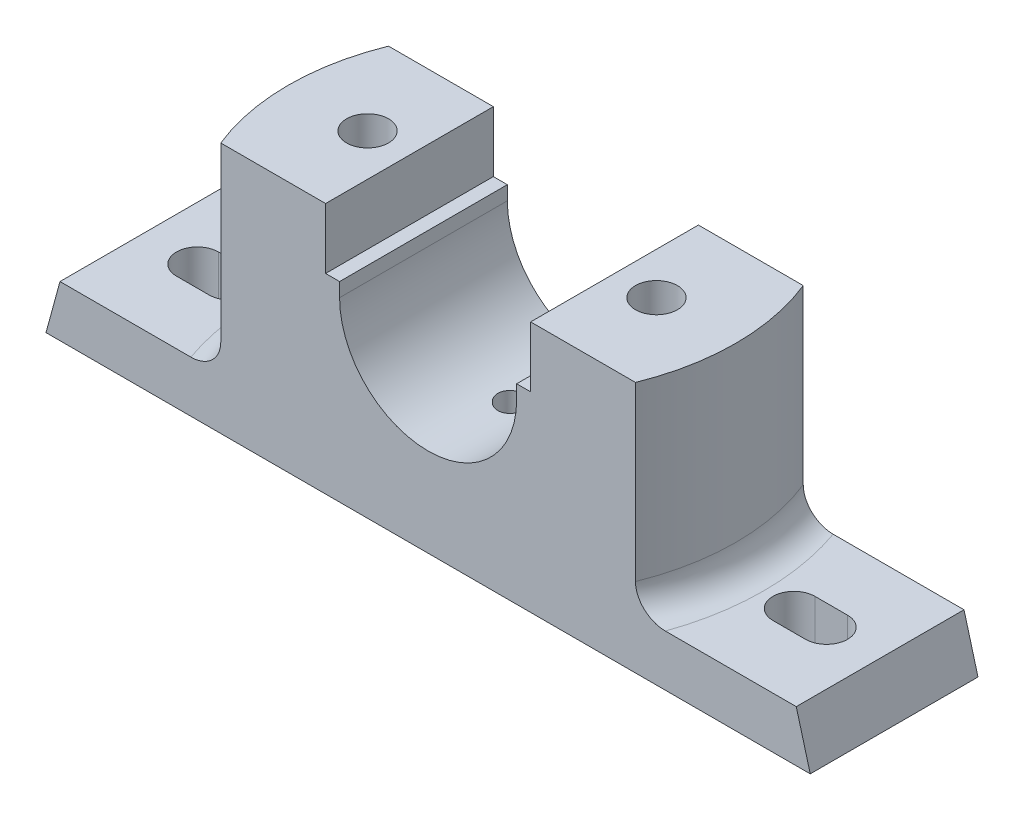
from build123d import *

# Parameters (mm, degrees)
BOSS_EXTRUDE1_DEPTH       = 18
CUT_EXTRUDE1_DEPTH        = 43
CUT_EXTRUDE2_DEPTH        = 12
SKETCH4_R                 = 4.5
CUT_EXTRUDE3_DEPTH        = 55
FILLET1_R                 = 6
SKETCH7_W                 = 20
SKETCH7_H                 = 20
CUT_EXTRUDE4_DEPTH        = 8
F_6_0MM_DOWEL_HOLE2_D     = 6
F_6_0MM_DOWEL_HOLE2_DEPTH = 6
F_6_0MM_DOWEL_HOLE2_TIP   = 1.802581857


with BuildPart() as part:
    # Sketch1 → Boss-Extrude1 (new body, symmetric)
    with BuildSketch(Plane.XY):
        with BuildLine():
            Line((-19, 3), (-22, 3))
            Line((-22, 3), (-22, 16))
            Line((-22, 16), (-50, 16))
            Line((-50, 16), (-50, -27))
            Line((-50, -27), (-79, -27))
            Line((-79, -27), (-82, -38))
            Line((-82, -38), (82, -38))
            Line((82, -38), (79, -27))
            Line((79, -27), (50, -27))
            Line((50, -27), (50, 16))
            Line((50, 16), (22, 16))
            Line((22, 16), (22, 3))
            Line((22, 3), (19, 3))
            Line((19, 3), (19, 0))
            ThreePointArc((19, 0), (0, -19), (-19, 0))
            Line((-19, 0), (-19, 3))
        make_face()
    extrude(amount=BOSS_EXTRUDE1_DEPTH, both=True)

    # Sketch2 → Cut-Extrude1 (cut)
    with BuildSketch(Plane(origin=(0, 16, 0), x_dir=(1, 0, 0), z_dir=(0, 1, 0))):
        with BuildLine():
            Line((-44.497190923, 18), (-50, 18))
            Line((-50, 18), (-50, -18))
            Line((-50, -18), (-44.497190923, -18))
            ThreePointArc((-44.497190923, -18), (-48, 0), (-44.497190923, 18))
        make_face()
    cut_extrude1 = extrude(amount=-CUT_EXTRUDE1_DEPTH, mode=Mode.SUBTRACT)

    # Mirror1: Cut-Extrude1 across plane
    add(cut_extrude1.mirror(Plane(origin=(0, 0, 0), x_dir=(0, 0, 1), z_dir=(1, 0, 0))), mode=Mode.SUBTRACT)

    # Sketch3 → Cut-Extrude2 (cut, through all)
    with BuildSketch(Plane(origin=(0, -27, 0), x_dir=(1, 0, 0), z_dir=(0, 1, 0))):
        with BuildLine():
            Line((-67.5, 4.5), (-60.5, 4.5))
            ThreePointArc((-60.5, 4.5), (-56, 0), (-60.5, -4.5))
            Line((-60.5, -4.5), (-67.5, -4.5))
            ThreePointArc((-67.5, -4.5), (-72, 0), (-67.5, 4.5))
        make_face()
    cut_extrude2 = extrude(amount=-CUT_EXTRUDE2_DEPTH, mode=Mode.SUBTRACT)

    # Mirror2: Cut-Extrude2 across plane
    add(cut_extrude2.mirror(Plane(origin=(0, 0, 0), x_dir=(0, 0, 1), z_dir=(1, 0, 0))), mode=Mode.SUBTRACT)

    # Sketch4 → Cut-Extrude3 (cut, through all)
    with BuildSketch(Plane(origin=(0, 16, 0), x_dir=(1, 0, 0), z_dir=(0, 1, 0))):
        with Locations(Location((-31, 0, 0), (0, 0, 180))):  # turned: the seam where the file's is
            Circle(SKETCH4_R)
    cut_extrude3 = extrude(amount=-CUT_EXTRUDE3_DEPTH, mode=Mode.SUBTRACT)

    # Mirror3: Cut-Extrude3 across plane
    add(cut_extrude3.mirror(Plane(origin=(0, 0, 0), x_dir=(0, 0, 1), z_dir=(1, 0, 0))), mode=Mode.SUBTRACT)

    # Fillet1
    fillet1_edges = [part.edges().sort_by_distance(p)[0] for p in [
        (-48, -27, 0),
        (48, -27, 0),
    ]]
    fillet(fillet1_edges, radius=FILLET1_R)

    # Sketch7 → Cut-Extrude4 (cut)
    with BuildSketch(Plane.XZ.offset(38)):
        with Locations((31, 0)):
            Rectangle(SKETCH7_W, SKETCH7_H)
    cut_extrude4 = extrude(amount=-CUT_EXTRUDE4_DEPTH, mode=Mode.SUBTRACT)

    # Mirror4: Cut-Extrude4 across plane
    add(cut_extrude4.mirror(Plane(origin=(0, 0, 0), x_dir=(0, 0, 1), z_dir=(1, 0, 0))), mode=Mode.SUBTRACT)

    # Ø6.0mm Dowel Hole2
    with Locations(Plane(origin=(0, -19, 0), x_dir=(1, 0, 0), z_dir=(0, 1, 0))):
        with Locations((0, 0)):
            Hole(F_6_0MM_DOWEL_HOLE2_D / 2, depth=F_6_0MM_DOWEL_HOLE2_DEPTH)
            with Locations((0, 0, -(F_6_0MM_DOWEL_HOLE2_DEPTH + F_6_0MM_DOWEL_HOLE2_TIP / 2))):  # 118° drill point
                Cone(0, F_6_0MM_DOWEL_HOLE2_D / 2, F_6_0MM_DOWEL_HOLE2_TIP, mode=Mode.SUBTRACT)


solid = part.part
